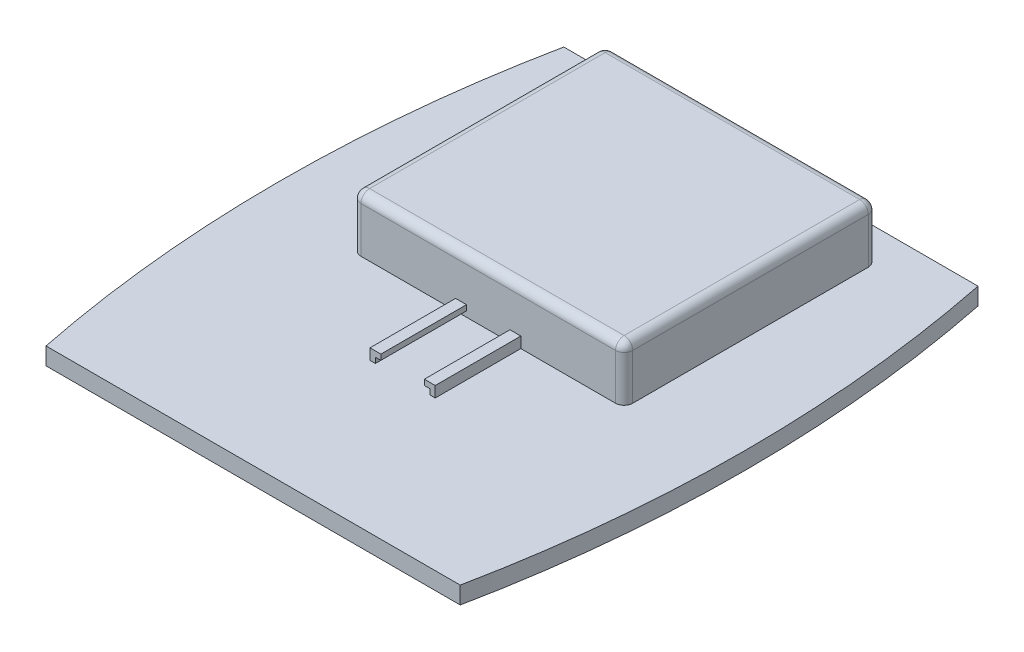
from build123d import *

# Parameters (mm, degrees)
BOSS_EXTRUDE1_DEPTH = 6.35
SKETCH2_W           = 100
SKETCH2_H           = 93
BOSS_EXTRUDE2_DEPTH = 20
FILLET1_R           = 3.175
BOSS_EXTRUDE3_DEPTH = 31.5
SKETCH5_W           = 35.56
SKETCH5_H           = 35.56
CUT_EXTRUDE1_DEPTH  = 0.254
LPATTERN1_COUNT     = 3
LPATTERN1_PITCH     = 45.72
LPATTERN2_COUNT     = 2
LPATTERN2_PITCH     = 45.72


with BuildPart() as part:
    # Sketch1 → Boss-Extrude1 (new body)
    with BuildSketch(Plane(origin=(0, 0, 0), x_dir=(1, 0, 0), z_dir=(0, 1, 0))):
        with BuildLine():
            Line((-76.2, 95.25), (76.2, 95.25))
            ThreePointArc((76.2, 95.25), (85.725, 0), (76.2, -95.25))
            Line((76.2, -95.25), (-76.2, -95.25))
            ThreePointArc((-76.2, -95.25), (-85.725, 0), (-76.2, 95.25))
        make_face()
    extrude(amount=BOSS_EXTRUDE1_DEPTH)

    # Sketch2 → Boss-Extrude2 (add)
    with BuildSketch(Plane(origin=(0, 6.35, 0), x_dir=(1, 0, 0), z_dir=(0, 1, 0))):
        with Locations((0, 37.75)):
            Rectangle(SKETCH2_W, SKETCH2_H)
    extrude(amount=BOSS_EXTRUDE2_DEPTH)

    # Fillet1
    fillet1_edges = [part.edges().sort_by_distance(p)[0] for p in [
        (50, 16.35, 8.75),
        (50, 16.35, -84.25),
        (-50, 16.35, -84.25),
        (-50, 16.35, 8.75),
        (50, 26.35, -37.75),
        (0, 26.35, -84.25),
        (-50, 26.35, -37.75),
        (0, 26.35, 8.75),
    ]]
    fillet(fillet1_edges, radius=FILLET1_R)

    # Sketch3 → Boss-Extrude3 (add)
    with BuildSketch(Plane.XY.offset(8.75)):
        Polygon((-12, 6.35), (-12, 10.35), (-8, 10.35), (-8, 8.35), (-10, 8.35), (-10, 6.35), align=None)
        Polygon((10, 6.35), (12, 6.35), (12, 10.35), (8, 10.35), (8, 8.35), (10, 8.35), align=None)
    extrude(amount=BOSS_EXTRUDE3_DEPTH)

    # Sketch5 → Cut-Extrude1 (cut)
    with BuildSketch(Plane.XZ):
        with Locations((-45.72, -22.86)):
            Rectangle(SKETCH5_W, SKETCH5_H)
        with Locations((0, -22.86)):
            Rectangle(SKETCH5_W, SKETCH5_H)
        with Locations((45.72, -22.86)):
            Rectangle(SKETCH5_W, SKETCH5_H)
    cut_extrude1 = extrude(amount=-CUT_EXTRUDE1_DEPTH, mode=Mode.SUBTRACT)

    # LPattern1: Cut-Extrude1 ×3
    with Locations(*[(0, 0, i * LPATTERN1_PITCH) for i in range(1, LPATTERN1_COUNT)]):
        add(cut_extrude1, mode=Mode.SUBTRACT)

    # LPattern2: Cut-Extrude1 ×2
    with Locations(*[(0, 0, -i * LPATTERN2_PITCH) for i in range(1, LPATTERN2_COUNT)]):
        add(cut_extrude1, mode=Mode.SUBTRACT)


solid = part.part
